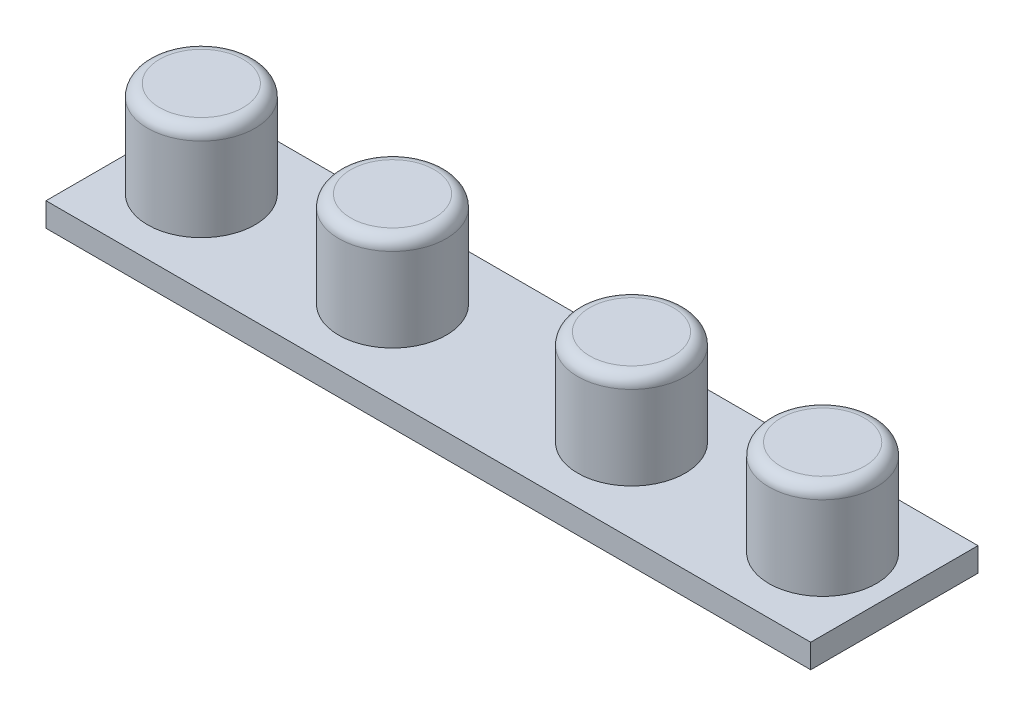
from build123d import *

# Parameters (mm, degrees)
SKETCH1_W           = 32
SKETCH1_H           = 7
BOSS_EXTRUDE1_DEPTH = 1
SKETCH2_R           = 2.25
BOSS_EXTRUDE2_DEPTH = 4
FILLET1_R           = 0.5


with BuildPart() as part:
    # Sketch1 → Boss-Extrude1 (new body)
    with BuildSketch(Plane(origin=(0, 0, 0), x_dir=(1, 0, 0), z_dir=(0, 1, 0))):
        Rectangle(SKETCH1_W, SKETCH1_H)
    extrude(amount=BOSS_EXTRUDE1_DEPTH)

    # Sketch2 → Boss-Extrude2 (add)
    with BuildSketch(Plane(origin=(0, 1, 0), x_dir=(1, 0, 0), z_dir=(0, 1, 0))):
        with Locations((-13, 0)):
            Circle(SKETCH2_R)
        with Locations((-5, 0)):
            Circle(SKETCH2_R)
        with Locations((5, 0)):
            Circle(SKETCH2_R)
        with Locations((13, 0)):
            Circle(SKETCH2_R)
    extrude(amount=BOSS_EXTRUDE2_DEPTH)

    # Fillet1
    fillet1_edges = [part.edges().sort_by_distance(p)[0] for p in [
        (-15.25, 5, 0),
        (-7.25, 5, 0),
        (2.75, 5, 0),
        (10.75, 5, 0),
    ]]
    fillet(fillet1_edges, radius=FILLET1_R)


solid = part.part
